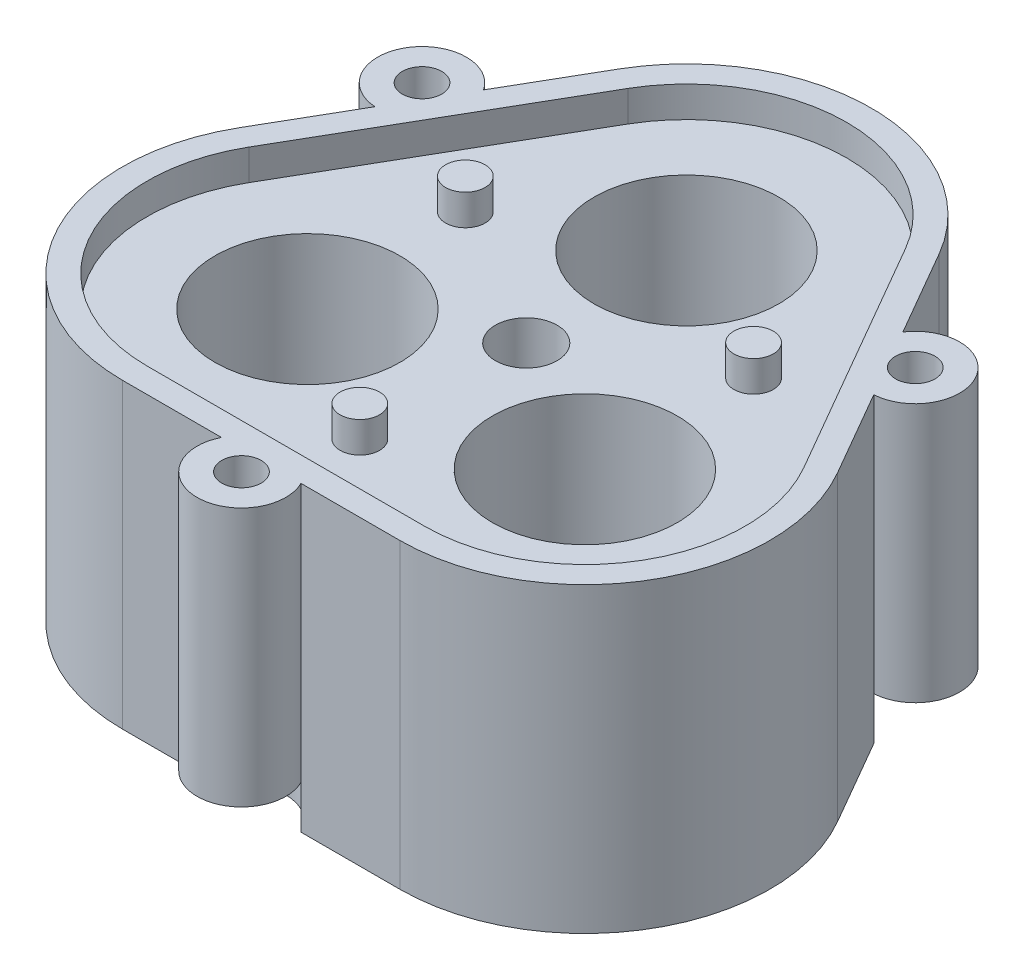
from build123d import *

# Parameters (mm, degrees)
SKETCH2_R               = 7.5
SKETCH2_R_2             = 2.5
BOSS_EXTRUDE1_DEPTH     = 12
SKETCH4_R               = 6
SKETCH4_R_2             = 2.5
BOSS_EXTRUDE2_DEPTH     = 8
SKETCH7_R               = 4
BOSS_EXTRUDE3_DEPTH     = 8
BOSS_EXTRUDE3_2_DEPTH   = 8
BOSS_EXTRUDE3_3_DEPTH   = 8
BOSS_EXTRUDE4_DEPTH     = 2
SKETCH10_R              = 0.75
SKETCH10_R_2            = 2.5
CUT_EXTRUDE2_DEPTH      = 21
CUT_EXTRUDE2_DEPTH_BACK = 3
SKETCH12_R              = 57.284308747
CUT_EXTRUDE3_DEPTH      = 1
CUT_EXTRUDE3_DEPTH_BACK = 23
SKETCH15_R              = 1.6
CUT_EXTRUDE4_DEPTH      = 21
CUT_EXTRUDE4_DEPTH_BACK = 3
SKETCH13_R              = 1.6
BOSS_EXTRUDE5_DEPTH     = 2.5
SKETCH16_R              = 3.6
SKETCH16_R_2            = 1.6
BOSS_EXTRUDE6_DEPTH     = 21
CUT_EXTRUDE10_START     = -1
SKETCH19_R              = 3.6
SKETCH19_R_2            = 1.6
CUT_EXTRUDE10_DEPTH     = 4.5
CIRPATTERN1_COUNT       = 3


with BuildPart() as part:
    # Sketch2 → Boss-Extrude1 (new body)
    with BuildSketch(Plane(origin=(0, 0, 0), x_dir=(1, 0, 0), z_dir=(0, 1, 0))):
        Polygon((-37.230762114, -21.495190528), (37.230762114, -21.495190528), (0, 42.990381057), align=None)
        with Locations((0, 12.990381057)):
            Circle(SKETCH2_R, mode=Mode.SUBTRACT)
        with Locations((-11.25, -6.495190528)):
            Circle(SKETCH2_R, mode=Mode.SUBTRACT)
        with Locations((11.25, -6.495190528)):
            Circle(SKETCH2_R, mode=Mode.SUBTRACT)
        Circle(SKETCH2_R_2, mode=Mode.SUBTRACT)
    extrude(amount=BOSS_EXTRUDE1_DEPTH)

    # Sketch4 → Boss-Extrude2 (add)
    with BuildSketch(Plane.XZ):
        Polygon((-37.230762114, 21.495190528), (37.230762114, 21.495190528), (0, -42.990381057), align=None)
        with Locations((-11.25, 6.495190528)):
            Circle(SKETCH4_R, mode=Mode.SUBTRACT)
        with Locations((11.25, 6.495190528)):
            Circle(SKETCH4_R, mode=Mode.SUBTRACT)
        with Locations((0, -12.990381057)):
            Circle(SKETCH4_R, mode=Mode.SUBTRACT)
        Circle(SKETCH4_R_2, mode=Mode.SUBTRACT)
    extrude(amount=BOSS_EXTRUDE2_DEPTH)



with BuildPart() as body_2:
    # Sketch7 → Boss-Extrude3 (new body)
    with BuildSketch(Plane(origin=(0, -8, 0), x_dir=(1, 0, 0), z_dir=(0, 1, 0))):
        with Locations((0, 12.990381057)):
            Circle(SKETCH7_R)
    extrude(amount=BOSS_EXTRUDE3_DEPTH)


with BuildPart() as body_3:
    # Sketch7 → Boss-Extrude3 2 (new body)
    with BuildSketch(Plane(origin=(0, -8, 0), x_dir=(1, 0, 0), z_dir=(0, 1, 0))):
        with Locations((-11.25, -6.495190528)):
            Circle(SKETCH7_R)
    extrude(amount=BOSS_EXTRUDE3_2_DEPTH)


with BuildPart() as body_4:
    # Sketch7 → Boss-Extrude3 3 (new body)
    with BuildSketch(Plane(origin=(0, -8, 0), x_dir=(1, 0, 0), z_dir=(0, 1, 0))):
        with Locations((11.25, -6.495190528)):
            Circle(SKETCH7_R)
    extrude(amount=BOSS_EXTRUDE3_3_DEPTH)


with BuildPart() as part_1:
    add(part.part)

    add(body_2.part)  # Boss-Extrude4 merges body 2

    add(body_3.part)  # Boss-Extrude4 merges body 3

    add(body_4.part)  # Boss-Extrude4 merges body 4
    # Sketch9 → Boss-Extrude4 (add)
    with BuildSketch(Plane(origin=(0, -8, 0), x_dir=(1, 0, 0), z_dir=(0, 1, 0))):
        Polygon((0, 42.990381057), (-37.230762114, -21.495190528), (37.230762114, -21.495190528), align=None)
    extrude(amount=-BOSS_EXTRUDE4_DEPTH)

    # Sketch10 → Cut-Extrude2 (cut, two sides)
    with BuildSketch(Plane(origin=(0, -8, 0), x_dir=(1, 0, 0), z_dir=(0, 1, 0))) as cut_extrude2_sk:
        with Locations((-8.385990432, -2.3967214)):
            Circle(SKETCH10_R)
        with Locations((-12.668631437, -1.700663978)):
            Circle(SKETCH10_R)
        with Locations((-6.260007048, -6.17900967)):
            Circle(SKETCH10_R)
        with Locations((-7.891590133, -10.199388575)):
            Circle(SKETCH10_R)
        with Locations((-12.052124348, -11.430430799)):
            Circle(SKETCH10_R)
        with Locations((-15.608642568, -8.945136439)):
            Circle(SKETCH10_R)
        with Locations((-15.883014034, -4.614982838)):
            Circle(SKETCH10_R)
        with Locations((2.117373598, 8.46084145)):
            Circle(SKETCH10_R)
        with Locations((4.86149751, 11.821688644)):
            Circle(SKETCH10_R)
        with Locations((-2.22117582, 8.510829966)):
            Circle(SKETCH10_R)
        with Locations((-4.887134542, 11.934011819)):
            Circle(SKETCH10_R)
        with Locations((-3.872981274, 16.152661254)):
            Circle(SKETCH10_R)
        with Locations((0.057605887, 17.990049202)):
            Circle(SKETCH10_R)
        with Locations((3.944814641, 16.062585062)):
            Circle(SKETCH10_R)
        with Locations((6.268616834, -6.06412005)):
            Circle(SKETCH10_R)
        with Locations((7.807133926, -10.121024667)):
            Circle(SKETCH10_R)
        with Locations((8.481182868, -2.331820296)):
            Circle(SKETCH10_R)
        with Locations((12.778724676, -1.734623244)):
            Circle(SKETCH10_R)
        with Locations((15.925105622, -4.722230455)):
            Circle(SKETCH10_R)
        with Locations((15.55103668, -9.044912763)):
            Circle(SKETCH10_R)
        with Locations((11.938199393, -11.447602223)):
            Circle(SKETCH10_R)
        Circle(SKETCH10_R_2)
    extrude(amount=CUT_EXTRUDE2_DEPTH, mode=Mode.SUBTRACT)
    extrude(cut_extrude2_sk.sketch, amount=-CUT_EXTRUDE2_DEPTH_BACK, mode=Mode.SUBTRACT)

    # Sketch12 → Cut-Extrude3 (cut, two sides)
    with BuildSketch(Plane(origin=(0, 12, 0), x_dir=(1, 0, 0), z_dir=(0, 1, 0))) as cut_extrude3_sk:
        Circle(SKETCH12_R)
        with BuildLine():
            Line((-12.990381057, 20.490381057), (-24.240381057, 1.004809472))
            ThreePointArc((-24.240381057, 1.004809472), (-24.240381057, -13.995190528), (-11.25, -21.495190528))
            Line((-11.25, -21.495190528), (11.25, -21.495190528))
            ThreePointArc((11.25, -21.495190528), (24.240381057, -13.995190528), (24.240381057, 1.004809472))
            Line((24.240381057, 1.004809472), (12.990381057, 20.490381057))
            ThreePointArc((12.990381057, 20.490381057), (0, 27.990381057), (-12.990381057, 20.490381057))
        make_face(mode=Mode.SUBTRACT)
    extrude(amount=CUT_EXTRUDE3_DEPTH, mode=Mode.SUBTRACT)
    extrude(cut_extrude3_sk.sketch, amount=-CUT_EXTRUDE3_DEPTH_BACK, mode=Mode.SUBTRACT)

    # Sketch15 → Cut-Extrude4 (cut, two sides)
    with BuildSketch(Plane(origin=(0, -8, 0), x_dir=(1, 0, 0), z_dir=(0, 1, 0))) as cut_extrude4_sk:
        with Locations((0, 12.990381057)):
            Circle(SKETCH15_R)
        with Locations((-11.25, -6.495190528)):
            Circle(SKETCH15_R)
        with Locations((11.25, -6.495190528)):
            Circle(SKETCH15_R)
    extrude(amount=CUT_EXTRUDE4_DEPTH, mode=Mode.SUBTRACT)
    extrude(cut_extrude4_sk.sketch, amount=-CUT_EXTRUDE4_DEPTH_BACK, mode=Mode.SUBTRACT)

    # Sketch13 → Boss-Extrude5 (add)
    with BuildSketch(Plane(origin=(0, 12, 0), x_dir=(1, 0, 0), z_dir=(0, 1, 0))):
        with BuildLine():
            Line((-12.990381057, 20.490381057), (-24.240381057, 1.004809472))
            ThreePointArc((-24.240381057, 1.004809472), (-24.240381057, -13.995190528), (-11.25, -21.495190528))
            Line((-11.25, -21.495190528), (11.25, -21.495190528))
            ThreePointArc((11.25, -21.495190528), (24.240381057, -13.995190528), (24.240381057, 1.004809472))
            Line((24.240381057, 1.004809472), (12.990381057, 20.490381057))
            ThreePointArc((12.990381057, 20.490381057), (0, 27.990381057), (-12.990381057, 20.490381057))
        make_face()
        with BuildLine():
            ThreePointArc((11.258330249, 19.490381057), (0, 25.990381057), (-11.258330249, 19.490381057))
            Line((-11.258330249, 19.490381057), (-22.508330249, 0.004809472))
            ThreePointArc((-22.508330249, 0.004809472), (-22.508330249, -12.995190528), (-11.25, -19.495190528))
            Line((-11.25, -19.495190528), (11.25, -19.495190528))
            ThreePointArc((11.25, -19.495190528), (22.508330249, -12.995190528), (22.508330249, 0.004809472))
            Line((22.508330249, 0.004809472), (11.258330249, 19.490381057))
        make_face(mode=Mode.SUBTRACT)
        with Locations((0, -13.495190528)):
            Circle(SKETCH13_R)
        with Locations((11.687177826, 6.747595264)):
            Circle(SKETCH13_R)
        with Locations((-11.687177826, 6.747595264)):
            Circle(SKETCH13_R)
    extrude(amount=BOSS_EXTRUDE5_DEPTH)

    # Sketch16 → Boss-Extrude6 (add)
    with BuildSketch(Plane(origin=(0, 14.5, 0), x_dir=(1, 0, 0), z_dir=(0, 1, 0))):
        with Locations((-20.001021703, 11.547595264)):
            Circle(SKETCH16_R)
        with Locations((-20.001021703, 11.547595264)):
            Circle(SKETCH16_R_2, mode=Mode.SUBTRACT)
        with Locations((20.001021703, 11.547595264)):
            Circle(SKETCH16_R)
        with Locations((20.001021703, 11.547595264)):
            Circle(SKETCH16_R_2, mode=Mode.SUBTRACT)
        with Locations((0, -23.095190528)):
            Circle(SKETCH16_R)
        with Locations((0, -23.095190528)):
            Circle(SKETCH16_R_2, mode=Mode.SUBTRACT)
    extrude(amount=-BOSS_EXTRUDE6_DEPTH)

    # Sketch19 → Cut-Extrude10 (cut)
    with BuildSketch(Plane(origin=(0, -10, 0), x_dir=(1, 0, 0), z_dir=(0, 1, 0)).offset(CUT_EXTRUDE10_START)):
        with Locations((20.001021703, 11.547595264)):
            Circle(SKETCH19_R)
        with Locations((20.001021703, 11.547595264)):
            Circle(SKETCH19_R_2, mode=Mode.SUBTRACT)
    cut_extrude10 = extrude(amount=CUT_EXTRUDE10_DEPTH, mode=Mode.SUBTRACT)

    # CirPattern1: Cut-Extrude10 ×3 about axis
    cirpattern1_axis = Axis((0, 0, 0), (0, 1, 0))
    for i in range(1, CIRPATTERN1_COUNT):
        add(cut_extrude10.rotate(cirpattern1_axis, i * 360 / CIRPATTERN1_COUNT), mode=Mode.SUBTRACT)


solid = part_1.part
